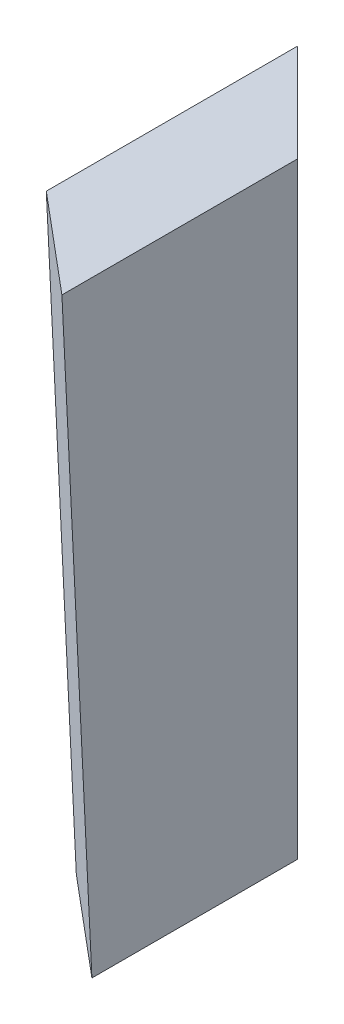
from build123d import *


with BuildPart() as part:
    # Croquis2 → Recubrir1 section 0
    with BuildSketch(Plane(origin=(0, 75, 0), x_dir=(1, 0, 0), z_dir=(0, 1, 0))):
        Polygon((9.875805492, -9.887487562), (-2.62, 2.62), (-2.62, -29.55), (9.875805492, -40.047487562), align=None)
    # Croquis1 → Recubrir1 section 1
    with BuildSketch(Plane(origin=(0, 0, 0), x_dir=(1, 0, 0), z_dir=(0, 1, 0))):
        Polygon((12.495805492, -38.827487562), (0, -28.33), (0, 0), (12.495805492, -12.507487562), align=None)
    loft()


solid = part.part
